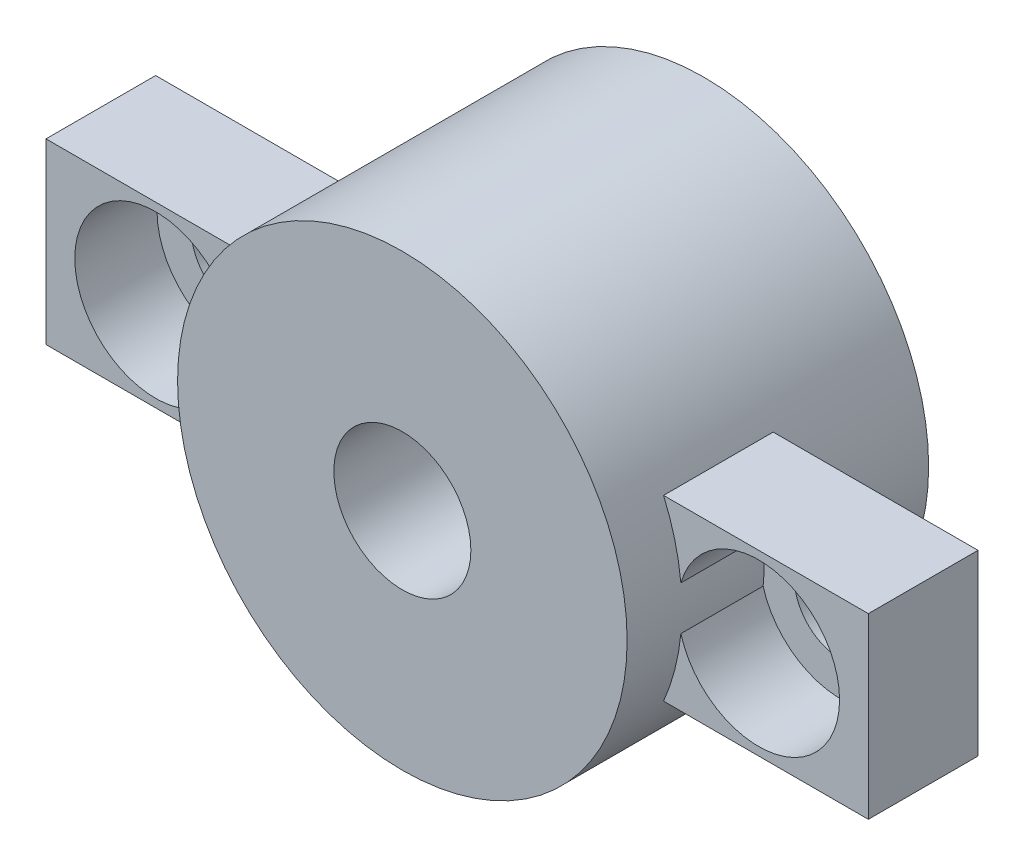
from build123d import *

# Parameters (mm, degrees)
CROQUIS1_R                   = 2.5
SALIENTE_EXTRUIR1_DEPTH      = 4
CROQUIS2_R                   = 1.7
CORTAR_EXTRUIR1_DEPTH        = 4
CROQUIS3_R                   = 2.95
CORTAR_EXTRUIR2_DEPTH        = 3
CROQUIS4_R                   = 8.2
CROQUIS4_R_2                 = 2.5
SALIENTE_EXTRUIR2_DEPTH      = 2
SALIENTE_EXTRUIR2_DEPTH_BACK = 9


with BuildPart() as part:
    # Croquis1 → Saliente-Extruir1 (new body)
    with BuildSketch(Plane.XY):
        with BuildLine():
            Line((-7.200520814, 3.25), (-15, 3.25))
            Line((-15, 3.25), (-15, -3.25))
            Line((-15, -3.25), (-7.200520814, -3.25))
            ThreePointArc((-7.200520814, -3.25), (0, -7.9), (7.200520814, -3.25))
            Line((7.200520814, -3.25), (15, -3.25))
            Line((15, -3.25), (15, 3.25))
            Line((15, 3.25), (7.200520814, 3.25))
            ThreePointArc((7.200520814, 3.25), (0, 7.9), (-7.200520814, 3.25))
        make_face()
        Circle(CROQUIS1_R, mode=Mode.SUBTRACT)
    extrude(amount=SALIENTE_EXTRUIR1_DEPTH)

    # Croquis2 → Cortar-Extruir1 (cut)
    with BuildSketch(Plane.XY.offset(4)):
        with Locations((-11, 0)):
            Circle(CROQUIS2_R)
        with Locations((11, 0)):
            Circle(CROQUIS2_R)
    extrude(amount=-CORTAR_EXTRUIR1_DEPTH, mode=Mode.SUBTRACT)

    # Croquis3 → Cortar-Extruir2 (cut)
    with BuildSketch(Plane.XY.offset(4)):
        with Locations((-11, 0)):
            Circle(CROQUIS3_R)
        with Locations((11, 0)):
            Circle(CROQUIS3_R)
    extrude(amount=-CORTAR_EXTRUIR2_DEPTH, mode=Mode.SUBTRACT)

    # Croquis4 → Saliente-Extruir2 (add, two sides)
    with BuildSketch(Plane.XY.offset(4)) as saliente_extruir2_sk:
        Circle(CROQUIS4_R)
        Circle(CROQUIS4_R_2, mode=Mode.SUBTRACT)
    extrude(amount=SALIENTE_EXTRUIR2_DEPTH)
    extrude(saliente_extruir2_sk.sketch, amount=-SALIENTE_EXTRUIR2_DEPTH_BACK)


solid = part.part
